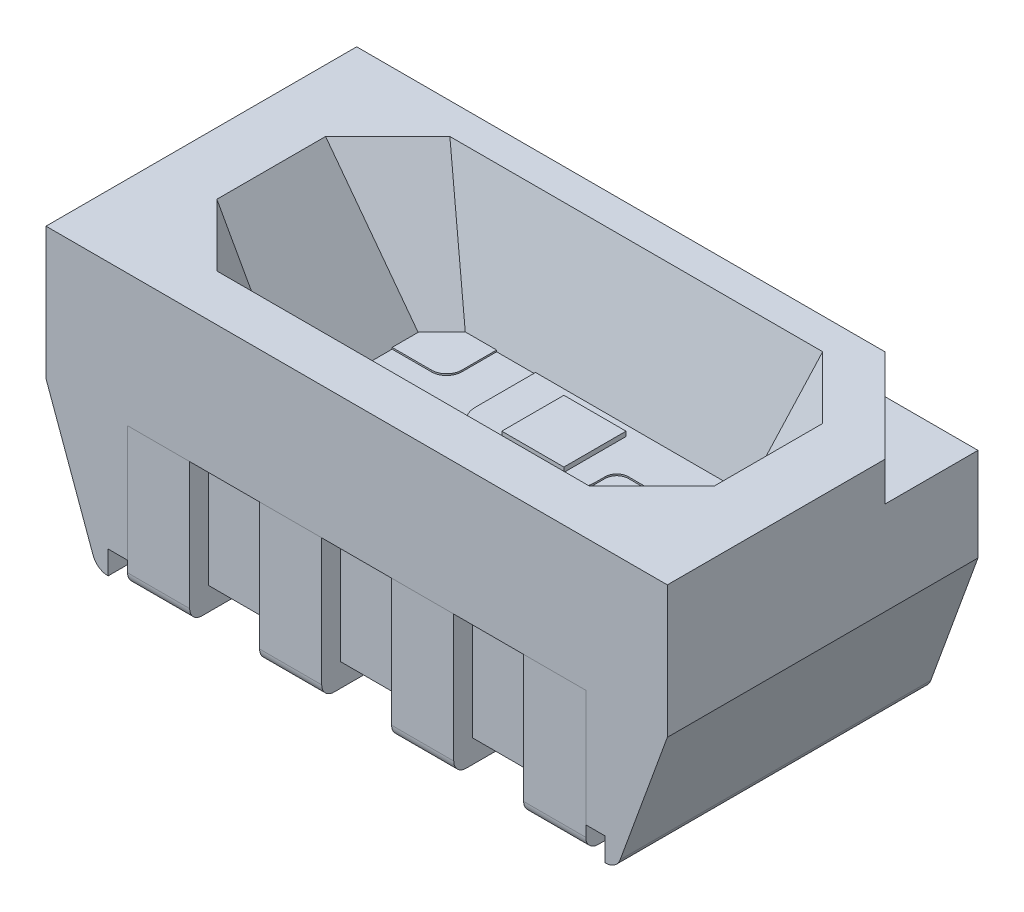
from build123d import *

# Parameters (mm, degrees)
SKETCH_1_W          = 4
SKETCH_1_H          = 2
EXTRUDE_1_DEPTH     = 1.75
CUT_EXTRUDE_1_REACH = 4
CUT_EXTRUDE_2_DEPTH = 0.25
FILLET_1_R          = 0.1
SKETCH_8_W          = 3.2
SKETCH_8_H          = 1
CUT_EXTRUDE_3_DEPTH = 0.15
SKETCH_9_W          = 2.95
SKETCH_9_H          = 0.12
CUT_EXTRUDE_4_DEPTH = 0.75
SKETCH_10_W         = 0.4
SKETCH_10_H         = 0.12
EXTRUDE_2_DEPTH     = 0.9
EXTRUDE_2_2_DEPTH   = 0.9
EXTRUDE_2_3_DEPTH   = 0.9
EXTRUDE_2_4_DEPTH   = 0.9
SKETCH_11_W         = 0.4
SKETCH_11_H         = 0.15
EXTRUDE_3_DEPTH     = 0.68
SKETCH_13_W         = 0.4
SKETCH_13_H         = 0.15
EXTRUDE_4_DEPTH     = 0.68
SKETCH_16_W         = 0.4
SKETCH_16_H         = 0.15
EXTRUDE_5_DEPTH     = 0.68
SKETCH_17_W         = 0.4
SKETCH_17_H         = 0.15
EXTRUDE_6_DEPTH     = 0.68
FILLET_2_R          = 0.08
FILLET_3_R          = 0.08
FILLET_4_R          = 0.08
FILLET_5_R          = 0.08
EXTRUDE_7_DEPTH     = 0.01
EXTRUDE_7_2_DEPTH   = 0.01
EXTRUDE_7_3_DEPTH   = 0.01
EXTRUDE_7_4_DEPTH   = 0.01
SKETCH_19_W         = 0.4
SKETCH_19_H         = 0.4
EXTRUDE_8_DEPTH     = 0.03


with BuildPart() as part:
    # Sketch 1 → Extrude 1 (new body)
    with BuildSketch(Plane(origin=(0, 0, 0), x_dir=(1, 0, 0), z_dir=(0, 1, 0))):
        with Locations((0, 1)):
            Rectangle(SKETCH_1_W, SKETCH_1_H)
    extrude(amount=EXTRUDE_1_DEPTH)

    # Sketch 2 → Cut-Extrude 1 (cut, up to next)
    with BuildSketch(Plane.XY, mode=Mode.PRIVATE) as cut_extrude_1_sk1:
        Polygon((-2, 0.9), (-1.672426789, 0), (-2, 0), align=None)
    cut_extrude_1_tool1 = extrude(cut_extrude_1_sk1.sketch, amount=-CUT_EXTRUDE_1_REACH, mode=Mode.PRIVATE) & part.part
    add(cut_extrude_1_tool1.solids().sort_by_distance((-1.890809, 0.3, 0))[0], mode=Mode.SUBTRACT)
    # Sketch 2 → Cut-Extrude 1 (cut, up to next)
    with BuildSketch(Plane.XY, mode=Mode.PRIVATE) as cut_extrude_1_sk2:
        Polygon((2, 0.9), (1.672426789, 0), (2, 0), align=None)
    cut_extrude_1_tool2 = extrude(cut_extrude_1_sk2.sketch, amount=-CUT_EXTRUDE_1_REACH, mode=Mode.PRIVATE) & part.part
    add(cut_extrude_1_tool2.solids().sort_by_distance((1.890809, 0.3, 0))[0], mode=Mode.SUBTRACT)

    # Sketch 6 → Loft 1 section 0
    with BuildSketch(Plane(origin=(0, 0.9, 0), x_dir=(1, 0, 0), z_dir=(0, 1, 0))):
        Polygon((-0.9, 1.6), (0.9, 1.6), (1.05, 1.45), (1.05, 0.65), (0.9, 0.5), (-0.9, 0.5), (-1.05, 0.65), (-1.05, 1.45), align=None)
    # Sketch 4 → Loft 1 section 1
    with BuildSketch(Plane(origin=(0, 1.75, 0), x_dir=(1, 0, 0), z_dir=(0, 1, 0))):
        Polygon((-1.6, 1.4), (-1.2, 1.8), (1.2, 1.8), (1.6, 1.4), (1.6, 0.7), (1.2, 0.3), (-1.2, 0.3), (-1.6, 0.7), align=None)
    loft(mode=Mode.SUBTRACT)

    # Sketch 7 → Cut-Extrude 2 (cut)
    with BuildSketch(Plane(origin=(0, 1.75, 0), x_dir=(1, 0, 0), z_dir=(0, 1, 0))):
        Polygon((2, 1.4), (1.4, 2), (2, 2), align=None)
    extrude(amount=-CUT_EXTRUDE_2_DEPTH, mode=Mode.SUBTRACT)

    # Fillet 1
    fillet_1_edges = [part.edges().sort_by_distance(p)[0] for p in [
        (-1.672426789, 0, -1),
        (1.672426789, 0, -1),
    ]]
    fillet(fillet_1_edges, radius=FILLET_1_R)

    # Sketch 8 → Cut-Extrude 3 (cut)
    with BuildSketch(Plane.XZ):
        with Locations((0, -0.5)):
            Rectangle(SKETCH_8_W, SKETCH_8_H)
    extrude(amount=-CUT_EXTRUDE_3_DEPTH, mode=Mode.SUBTRACT)

    # Sketch 9 → Cut-Extrude 4 (cut)
    with BuildSketch(Plane.XZ.offset(-0.15)):
        with Locations((0, -0.06)):
            Rectangle(SKETCH_9_W, SKETCH_9_H)
    extrude(amount=-CUT_EXTRUDE_4_DEPTH, mode=Mode.SUBTRACT)


with BuildPart() as body_2:
    # Sketch 10 → Extrude 2 (new body)
    with BuildSketch(Plane.XZ.offset(-0.9)):
        with Locations((-1.275, -0.06)):
            Rectangle(SKETCH_10_W, SKETCH_10_H)
    extrude(amount=EXTRUDE_2_DEPTH)


with BuildPart() as body_3:
    # Sketch 10 → Extrude 2 2 (new body)
    with BuildSketch(Plane.XZ.offset(-0.9)):
        with Locations((-0.425, -0.06)):
            Rectangle(SKETCH_10_W, SKETCH_10_H)
    extrude(amount=EXTRUDE_2_2_DEPTH)


with BuildPart() as body_4:
    # Sketch 10 → Extrude 2 3 (new body)
    with BuildSketch(Plane.XZ.offset(-0.9)):
        with Locations((0.425, -0.06)):
            Rectangle(SKETCH_10_W, SKETCH_10_H)
    extrude(amount=EXTRUDE_2_3_DEPTH)


with BuildPart() as body_5:
    # Sketch 10 → Extrude 2 4 (new body)
    with BuildSketch(Plane.XZ.offset(-0.9)):
        with Locations((1.275, -0.06)):
            Rectangle(SKETCH_10_W, SKETCH_10_H)
    extrude(amount=EXTRUDE_2_4_DEPTH)


with BuildPart() as body_6:
    # Sketch 11 → Extrude 3 (new body)
    with BuildSketch(Plane(origin=(0, 0, -0.12), x_dir=(-1, 0, 0), z_dir=(0, 0, -1))):
        with Locations((-1.275, 0.075)):
            Rectangle(SKETCH_11_W, SKETCH_11_H)
    extrude(amount=EXTRUDE_3_DEPTH)


with BuildPart() as body_7:
    # Sketch 13 → Extrude 4 (new body)
    with BuildSketch(Plane(origin=(0, 0, -0.12), x_dir=(-1, 0, 0), z_dir=(0, 0, -1))):
        with Locations((-0.425, 0.075)):
            Rectangle(SKETCH_13_W, SKETCH_13_H)
    extrude(amount=EXTRUDE_4_DEPTH)


with BuildPart() as body_8:
    # Sketch 16 → Extrude 5 (new body)
    with BuildSketch(Plane(origin=(0, 0, -0.12), x_dir=(-1, 0, 0), z_dir=(0, 0, -1))):
        with Locations((0.425, 0.075)):
            Rectangle(SKETCH_16_W, SKETCH_16_H)
    extrude(amount=EXTRUDE_5_DEPTH)


with BuildPart() as body_9:
    # Sketch 17 → Extrude 6 (new body)
    with BuildSketch(Plane(origin=(0, 0, -0.12), x_dir=(-1, 0, 0), z_dir=(0, 0, -1))):
        with Locations((1.275, 0.075)):
            Rectangle(SKETCH_17_W, SKETCH_17_H)
    extrude(amount=EXTRUDE_6_DEPTH)


with BuildPart() as body_5_1:
    add(body_5.part)

    # Combine 2: union body 6
    add(body_6.part)

    # Fillet 2
    fillet_2_edges = [body_5_1.edges().sort_by_distance(p)[0] for p in [
        (1.275, 0, 0),
    ]]
    fillet(fillet_2_edges, radius=FILLET_2_R)


with BuildPart() as body_2_1:
    add(body_2.part)

    # Combine 3: union body 9
    add(body_9.part)

    # Fillet 5
    fillet_5_edges = [body_2_1.edges().sort_by_distance(p)[0] for p in [
        (-1.275, 0, 0),
    ]]
    fillet(fillet_5_edges, radius=FILLET_5_R)


with BuildPart() as body_4_1:
    add(body_4.part)

    # Combine 6: union body 7
    add(body_7.part)

    # Fillet 3
    fillet_3_edges = [body_4_1.edges().sort_by_distance(p)[0] for p in [
        (0.425, 0, 0),
    ]]
    fillet(fillet_3_edges, radius=FILLET_3_R)


with BuildPart() as body_3_1:
    add(body_3.part)

    # Combine 7: union body 8
    add(body_8.part)

    # Fillet 4
    fillet_4_edges = [body_3_1.edges().sort_by_distance(p)[0] for p in [
        (-0.425, 0, 0),
    ]]
    fillet(fillet_4_edges, radius=FILLET_4_R)


with BuildPart() as body_6_2:
    # Sketch 18 → Extrude 7 (new body)
    with BuildSketch(Plane(origin=(0, 0.9, 0), x_dir=(1, 0, 0), z_dir=(0, 1, 0))):
        with BuildLine():
            Line((1.05, 1.45), (0.9, 1.6))
            Line((0.9, 1.6), (-0.448423463, 1.6))
            Line((-0.448423463, 1.6), (-0.448423463, 1.212059073))
            ThreePointArc((-0.448423463, 1.212059073), (-0.408063152, 1.114620663), (-0.310624741, 1.074260352))
            Line((-0.310624741, 1.074260352), (0.258908283, 1.074260352))
            ThreePointArc((0.258908283, 1.074260352), (0.32796203, 1.10286335), (0.356565028, 1.171917097))
            Line((0.356565028, 1.171917097), (0.356565028, 1.242938885))
            ThreePointArc((0.356565028, 1.242938885), (0.378443208, 1.295757483), (0.431261807, 1.317635663))
            Line((0.431261807, 1.317635663), (1.05, 1.317635663))
            Line((1.05, 1.317635663), (1.05, 1.45))
        make_face()
    extrude(amount=EXTRUDE_7_DEPTH)


with BuildPart() as body_7_2:
    # Sketch 18 → Extrude 7 2 (new body)
    with BuildSketch(Plane(origin=(0, 0.9, 0), x_dir=(1, 0, 0), z_dir=(0, 1, 0))):
        with BuildLine():
            Line((1.05, 0.65), (1.05, 1.136407249))
            Line((1.05, 1.136407249), (0.602120574, 1.136407249))
            ThreePointArc((0.602120574, 1.136407249), (0.501770239, 1.094840779), (0.46020377, 0.994490444))
            Line((0.46020377, 0.994490444), (0.46020377, 0.5))
            Line((0.46020377, 0.5), (0.9, 0.5))
            Line((0.9, 0.5), (1.05, 0.65))
        make_face()
    extrude(amount=EXTRUDE_7_2_DEPTH)


with BuildPart() as body_8_2:
    # Sketch 18 → Extrude 7 3 (new body)
    with BuildSketch(Plane(origin=(0, 0.9, 0), x_dir=(1, 0, 0), z_dir=(0, 1, 0))):
        with BuildLine():
            Line((-0.9, 0.5), (0.240206256, 0.5))
            Line((0.240206256, 0.5), (0.240206256, 0.876622221))
            Line((0.240206256, 0.876622221), (-0.506383258, 0.876622221))
            ThreePointArc((-0.506383258, 0.876622221), (-0.534302481, 0.888186742), (-0.545867002, 0.916105964))
            Line((-0.545867002, 0.916105964), (-0.545867002, 0.966443449))
            ThreePointArc((-0.545867002, 0.966443449), (-0.564154154, 1.010592542), (-0.608303247, 1.028879695))
            Line((-0.608303247, 1.028879695), (-1.05, 1.028879695))
            Line((-1.05, 1.028879695), (-1.05, 0.65))
            Line((-1.05, 0.65), (-0.9, 0.5))
        make_face()
    extrude(amount=EXTRUDE_7_3_DEPTH)


with BuildPart() as body_9_2:
    # Sketch 18 → Extrude 7 4 (new body)
    with BuildSketch(Plane(origin=(0, 0.9, 0), x_dir=(1, 0, 0), z_dir=(0, 1, 0))):
        with BuildLine():
            Line((-1.05, 1.45), (-1.05, 1.278241059))
            Line((-1.05, 1.278241059), (-0.79630602, 1.278241059))
            ThreePointArc((-0.79630602, 1.278241059), (-0.727464657, 1.306756085), (-0.69894963, 1.375597448))
            Line((-0.69894963, 1.375597448), (-0.69894963, 1.6))
            Line((-0.69894963, 1.6), (-0.9, 1.6))
            Line((-0.9, 1.6), (-1.05, 1.45))
        make_face()
    extrude(amount=EXTRUDE_7_4_DEPTH)


with BuildPart() as body_10:
    # Sketch 19 → Extrude 8 (new body)
    with BuildSketch(Plane(origin=(0, 0.91, 0), x_dir=(1, 0, 0), z_dir=(0, 1, 0))):
        with Locations((0, 1.334128878)):
            Rectangle(SKETCH_19_W, SKETCH_19_H)
    extrude(amount=EXTRUDE_8_DEPTH)


solid = Compound([part.part, body_5_1.part, body_2_1.part, body_4_1.part, body_3_1.part, body_6_2.part, body_7_2.part, body_8_2.part, body_9_2.part, body_10.part])
